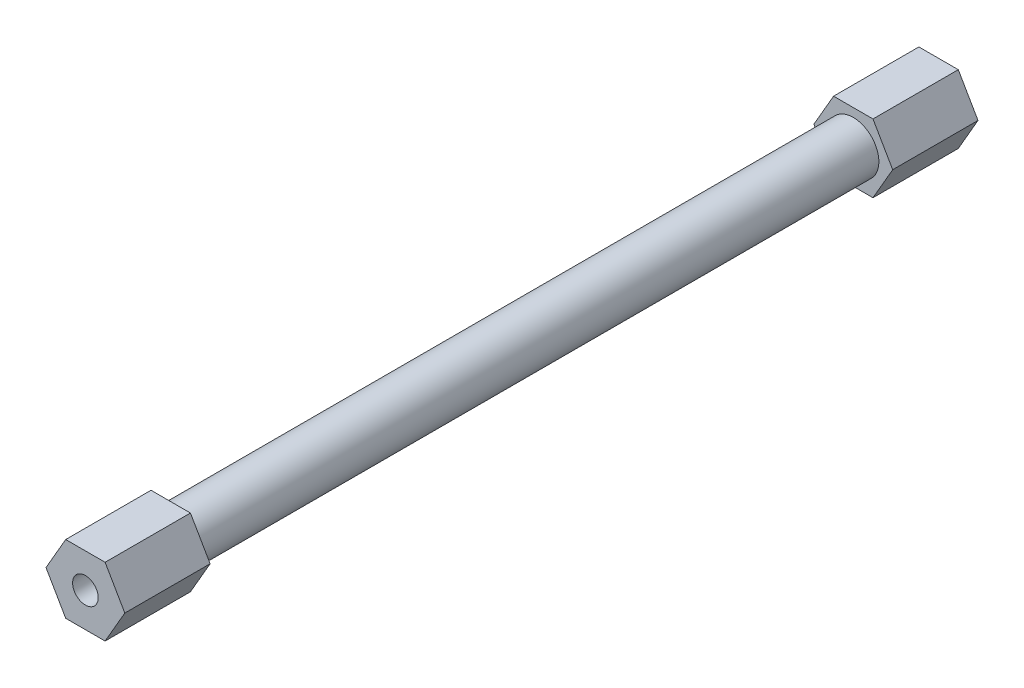
from build123d import *

# Parameters (mm, degrees)
SKETCH1_R           = 3
SKETCH1_R_2         = 1.5
BOSS_EXTRUDE1_DEPTH = 100
SKETCH2_R           = 1.5
BOSS_EXTRUDE2_DEPTH = 10


with BuildPart() as part:
    # Sketch1 → Boss-Extrude1 (new body)
    with BuildSketch(Plane.XY):
        Circle(SKETCH1_R)
        Circle(SKETCH1_R_2, mode=Mode.SUBTRACT)
    extrude(amount=BOSS_EXTRUDE1_DEPTH)

    # Sketch2 → Boss-Extrude2 (add)
    with BuildSketch(Plane.XY.offset(100)):
        Polygon((4.618802154, 0), (2.309401077, 4), (-2.309401077, 4), (-4.618802154, 0), (-2.309401077, -4), (2.309401077, -4), align=None)
        Circle(SKETCH2_R, mode=Mode.SUBTRACT)
    boss_extrude2 = extrude(amount=-BOSS_EXTRUDE2_DEPTH)

    # Mirror1: Boss-Extrude2 across plane
    add(boss_extrude2.mirror(Plane.XY.offset(50)))


solid = part.part
